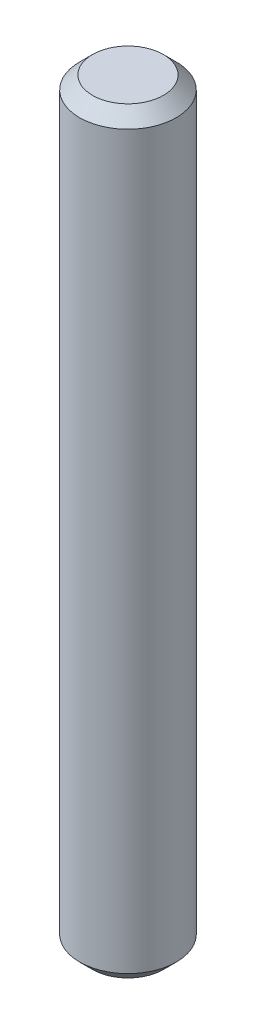
from build123d import *

# Parameters (mm, degrees)
SKETCH1_R           = 1.5
BOSS_EXTRUDE1_DEPTH = 11.75
CHAMFER1_SIZE       = 0.4


with BuildPart() as part:
    # Sketch1 → Boss-Extrude1 (new body, symmetric)
    with BuildSketch(Plane(origin=(0, 0, 0), x_dir=(1, 0, 0), z_dir=(0, 1, 0))):
        Circle(SKETCH1_R)
    extrude(amount=BOSS_EXTRUDE1_DEPTH, both=True)

    # Chamfer1
    chamfer1_edges = [part.edges().sort_by_distance(p)[0] for p in [
        (-1.5, -11.75, 0),
        (-1.5, 11.75, 0),
    ]]
    chamfer(chamfer1_edges, length=CHAMFER1_SIZE)


solid = part.part
